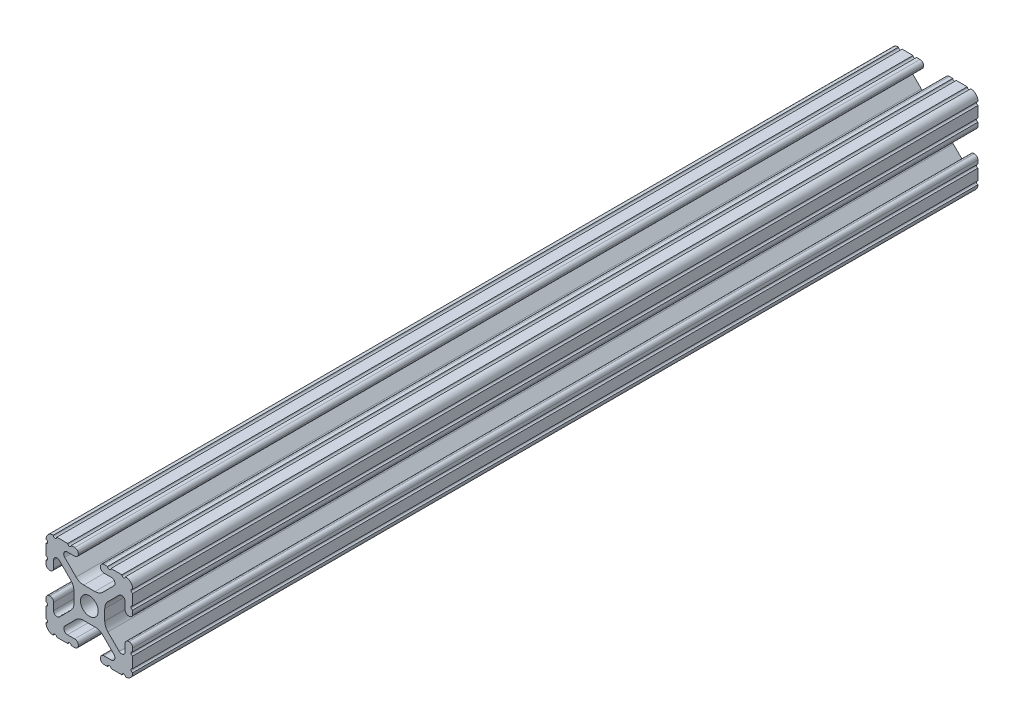
from build123d import *

# Parameters (mm, degrees)
SKETCH1_R           = 2.6035
BOSS_EXTRUDE1_DEPTH = 123.825


with BuildPart() as part:
    # Sketch1 → Boss-Extrude1 (new body, symmetric)
    with BuildSketch(Plane.XY):
        with BuildLine():
            Line((-7.179650497, -8.645192506), (-3.952270251, -5.423690499))
            ThreePointArc((-3.952270251, -5.423690499), (-2.922936451, -4.736929036), (-1.709253557, -4.4958))
            Line((-1.709253557, -4.4958), (1.709253557, -4.4958))
            ThreePointArc((1.709253557, -4.4958), (2.922936451, -4.736929036), (3.952270251, -5.423690499))
            Line((3.952270251, -5.423690499), (7.179650497, -8.645192506))
            ThreePointArc((7.179650497, -8.645192506), (7.41473083, -9.822813117), (6.416408329, -10.4902))
            Line((6.416408329, -10.4902), (4.287512407, -10.4902))
            ThreePointArc((4.287512407, -10.4902), (3.54574862, -10.79744862), (3.2385, -11.539212407))
            Line((3.2385, -11.539212407), (3.2385, -11.650987593))
            ThreePointArc((3.2385, -11.650987593), (3.54574862, -12.39275138), (4.287512407, -12.7))
            Line((4.287512407, -12.7), (5.317126718, -12.7))
            ThreePointArc((5.317126718, -12.7), (5.825126718, -12.192), (6.333126718, -12.7))
            Line((6.333126718, -12.7), (9.550443118, -12.7))
            ThreePointArc((9.550443118, -12.7), (10.058366869, -12.192000006), (10.566443095, -12.699847501))
            ThreePointArc((10.566443095, -12.699847501), (12.082537762, -12.08250727), (12.699846982, -10.566399977))
            ThreePointArc((12.699846982, -10.566399977), (12.192000006, -10.058323491), (12.7, -9.5504))
            Line((12.7, -9.5504), (12.7, -6.3330836))
            ThreePointArc((12.7, -6.3330836), (12.192, -5.8250836), (12.7, -5.3170836))
            Line((12.7, -5.3170836), (12.7, -4.287469289))
            ThreePointArc((12.7, -4.287469289), (12.39275138, -3.545705502), (11.650987593, -3.238456882))
            Line((11.650987593, -3.238456882), (11.539212407, -3.238456882))
            ThreePointArc((11.539212407, -3.238456882), (10.79744862, -3.545705502), (10.4902, -4.287469289))
            Line((10.4902, -4.287469289), (10.4902, -6.402089023))
            ThreePointArc((10.4902, -6.402089023), (9.856505071, -7.351067942), (8.737131347, -7.129408934))
            Line((8.737131347, -7.129408934), (5.441005833, -3.840816462))
            ThreePointArc((5.441005833, -3.840816462), (4.750877967, -2.809883091), (4.5085, -1.593185507))
            Line((4.5085, -1.593185507), (4.5085, 1.593185507))
            ThreePointArc((4.5085, 1.593185507), (4.750877967, 2.809883091), (5.441005833, 3.840816462))
            Line((5.441005833, 3.840816462), (8.737131347, 7.129408934))
            ThreePointArc((8.737131347, 7.129408934), (9.856505071, 7.351067942), (10.4902, 6.402089023))
            Line((10.4902, 6.402089023), (10.4902, 4.287469289))
            ThreePointArc((10.4902, 4.287469289), (10.79744862, 3.545705502), (11.539212407, 3.238456882))
            Line((11.539212407, 3.238456882), (11.650987593, 3.238456882))
            ThreePointArc((11.650987593, 3.238456882), (12.39275138, 3.545705502), (12.7, 4.287469289))
            Line((12.7, 4.287469289), (12.7, 5.3170836))
            ThreePointArc((12.7, 5.3170836), (12.192, 5.8250836), (12.7, 6.3330836))
            Line((12.7, 6.3330836), (12.7, 9.5504))
            ThreePointArc((12.7, 9.5504), (12.192000006, 10.058323491), (12.699846982, 10.566399977))
            ThreePointArc((12.699846982, 10.566399977), (12.082537762, 12.08250727), (10.566443095, 12.699847501))
            ThreePointArc((10.566443095, 12.699847501), (10.058366869, 12.192000006), (9.550443118, 12.7))
            Line((9.550443118, 12.7), (6.333126718, 12.7))
            ThreePointArc((6.333126718, 12.7), (5.825126718, 12.192), (5.317126718, 12.7))
            Line((5.317126718, 12.7), (4.287512407, 12.7))
            ThreePointArc((4.287512407, 12.7), (3.54574862, 12.39275138), (3.2385, 11.650987593))
            Line((3.2385, 11.650987593), (3.2385, 11.539212407))
            ThreePointArc((3.2385, 11.539212407), (3.54574862, 10.79744862), (4.287512407, 10.4902))
            Line((4.287512407, 10.4902), (6.476788598, 10.4902))
            ThreePointArc((6.476788598, 10.4902), (7.432222385, 9.85140422), (7.207036008, 8.724370562))
            Line((7.207036008, 8.724370562), (3.898272566, 5.423169045))
            ThreePointArc((3.898272566, 5.423169045), (2.869120213, 4.736787962), (1.655778399, 4.4958))
            Line((1.655778399, 4.4958), (-1.655778399, 4.4958))
            ThreePointArc((-1.655778399, 4.4958), (-2.869120213, 4.736787962), (-3.898272566, 5.423169045))
            Line((-3.898272566, 5.423169045), (-7.207036008, 8.724370562))
            ThreePointArc((-7.207036008, 8.724370562), (-7.432222385, 9.85140422), (-6.476788598, 10.4902))
            Line((-6.476788598, 10.4902), (-4.287512407, 10.4902))
            ThreePointArc((-4.287512407, 10.4902), (-3.54574862, 10.79744862), (-3.2385, 11.539212407))
            Line((-3.2385, 11.539212407), (-3.2385, 11.650987593))
            ThreePointArc((-3.2385, 11.650987593), (-3.54574862, 12.39275138), (-4.287512407, 12.7))
            Line((-4.287512407, 12.7), (-5.317126718, 12.7))
            ThreePointArc((-5.317126718, 12.7), (-5.825126718, 12.192), (-6.333126718, 12.7))
            Line((-6.333126718, 12.7), (-9.550443118, 12.7))
            ThreePointArc((-9.550443118, 12.7), (-10.058366869, 12.192000006), (-10.566443095, 12.699847501))
            ThreePointArc((-10.566443095, 12.699847501), (-12.082537762, 12.08250727), (-12.699846982, 10.566399977))
            ThreePointArc((-12.699846982, 10.566399977), (-12.192000006, 10.058323491), (-12.7, 9.5504))
            Line((-12.7, 9.5504), (-12.7, 6.3330836))
            ThreePointArc((-12.7, 6.3330836), (-12.192, 5.8250836), (-12.7, 5.3170836))
            Line((-12.7, 5.3170836), (-12.7, 4.287469289))
            ThreePointArc((-12.7, 4.287469289), (-12.39275138, 3.545705502), (-11.650987593, 3.238456882))
            Line((-11.650987593, 3.238456882), (-11.539212407, 3.238456882))
            ThreePointArc((-11.539212407, 3.238456882), (-10.79744862, 3.545705502), (-10.4902, 4.287469289))
            Line((-10.4902, 4.287469289), (-10.4902, 6.402089023))
            ThreePointArc((-10.4902, 6.402089023), (-9.856505071, 7.351067942), (-8.737131347, 7.129408934))
            Line((-8.737131347, 7.129408934), (-5.441005833, 3.840816462))
            ThreePointArc((-5.441005833, 3.840816462), (-4.750877967, 2.809883091), (-4.5085, 1.593185507))
            Line((-4.5085, 1.593185507), (-4.5085, -1.593185507))
            ThreePointArc((-4.5085, -1.593185507), (-4.750877967, -2.809883091), (-5.441005833, -3.840816462))
            Line((-5.441005833, -3.840816462), (-8.737131347, -7.129408934))
            ThreePointArc((-8.737131347, -7.129408934), (-9.856505071, -7.351067942), (-10.4902, -6.402089023))
            Line((-10.4902, -6.402089023), (-10.4902, -4.287469289))
            ThreePointArc((-10.4902, -4.287469289), (-10.79744862, -3.545705502), (-11.539212407, -3.238456882))
            Line((-11.539212407, -3.238456882), (-11.650987593, -3.238456882))
            ThreePointArc((-11.650987593, -3.238456882), (-12.39275138, -3.545705502), (-12.7, -4.287469289))
            Line((-12.7, -4.287469289), (-12.7, -5.3170836))
            ThreePointArc((-12.7, -5.3170836), (-12.192, -5.8250836), (-12.7, -6.3330836))
            Line((-12.7, -6.3330836), (-12.7, -9.5504))
            ThreePointArc((-12.7, -9.5504), (-12.192000006, -10.058323491), (-12.699846982, -10.566399977))
            ThreePointArc((-12.699846982, -10.566399977), (-12.082537762, -12.08250727), (-10.566443095, -12.699847501))
            ThreePointArc((-10.566443095, -12.699847501), (-10.058366869, -12.192000006), (-9.550443118, -12.7))
            Line((-9.550443118, -12.7), (-6.333126718, -12.7))
            ThreePointArc((-6.333126718, -12.7), (-5.825126718, -12.192), (-5.317126718, -12.7))
            Line((-5.317126718, -12.7), (-4.287512407, -12.7))
            ThreePointArc((-4.287512407, -12.7), (-3.54574862, -12.39275138), (-3.2385, -11.650987593))
            Line((-3.2385, -11.650987593), (-3.2385, -11.539212407))
            ThreePointArc((-3.2385, -11.539212407), (-3.54574862, -10.79744862), (-4.287512407, -10.4902))
            Line((-4.287512407, -10.4902), (-6.416408329, -10.4902))
            ThreePointArc((-6.416408329, -10.4902), (-7.41473083, -9.822813117), (-7.179650497, -8.645192506))
        make_face()
        Circle(SKETCH1_R, mode=Mode.SUBTRACT)
    extrude(amount=BOSS_EXTRUDE1_DEPTH, both=True)


solid = part.part
